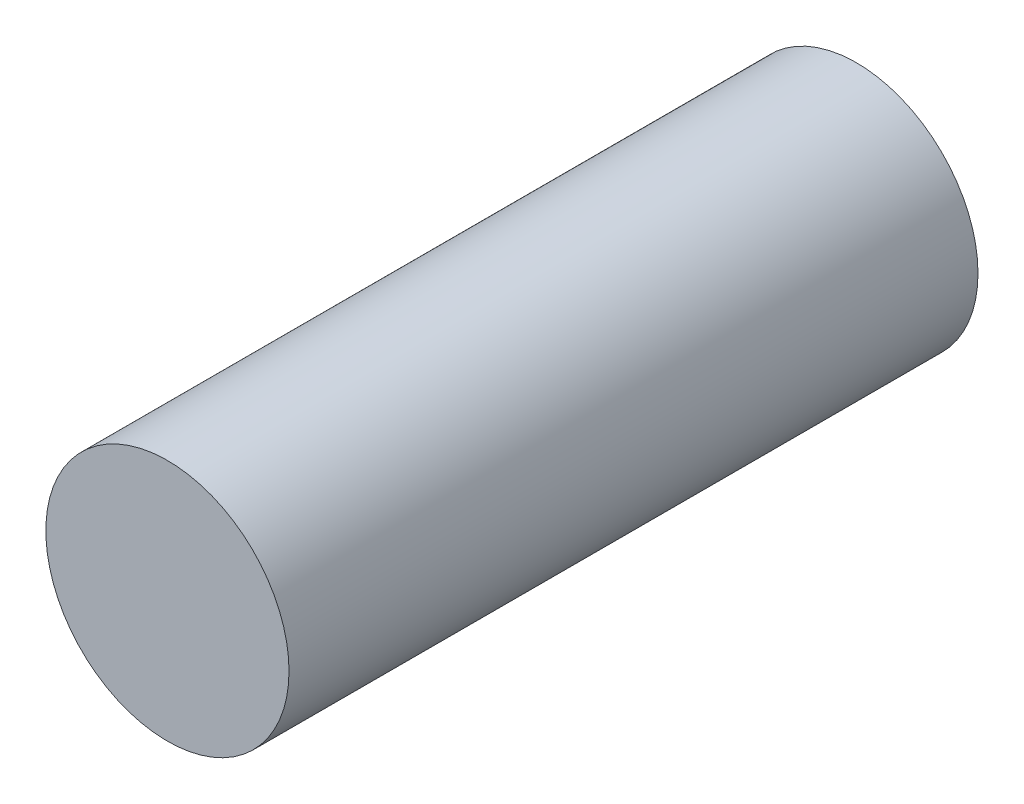
from build123d import *

# Parameters (mm, degrees)
SKETCH_1_R      = 3
EXTRUDE_1_DEPTH = 17


with BuildPart() as part:
    # ｽｹｯﾁ1 → ﾎﾞｽ - 押し出し1 (new body)
    with BuildSketch(Plane.XY):
        with Locations((8, 46)):
            Circle(SKETCH_1_R)
    extrude(amount=EXTRUDE_1_DEPTH)


solid = part.part
